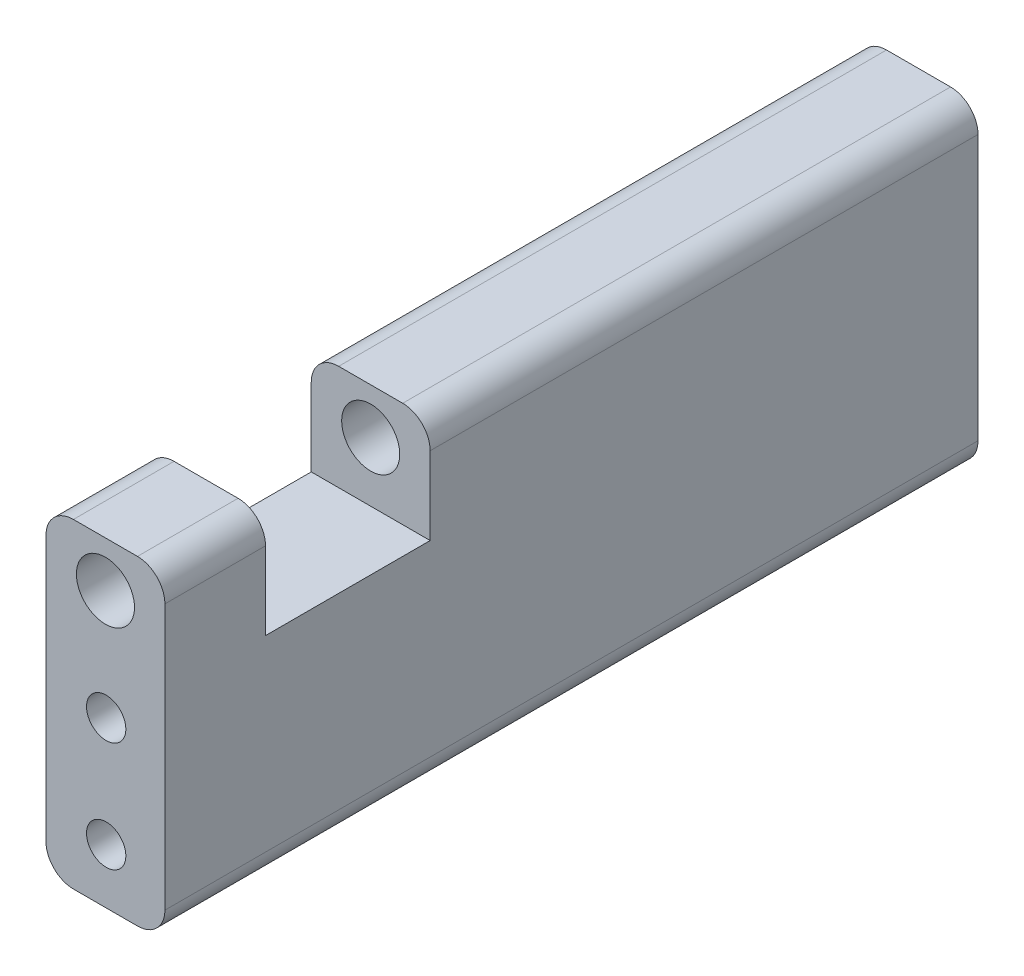
from build123d import *

# Parameters (mm, degrees)
SKETCH1_W                = 13
SKETCH1_H                = 35
SKETCH1_R                = 3.175
BOSS_EXTRUDE1_DEPTH      = 88.9
CUT_EXTRUDE1_DEPTH       = 9
M4_CLEARANCE_HOLE1_D     = 4.3
M4_CLEARANCE_HOLE1_DEPTH = 5
M4_CLEARANCE_HOLE1_TIP   = 1.291850331
M4_CLEARANCE_HOLE2_D     = 4.3
M4_CLEARANCE_HOLE2_DEPTH = 5
M4_CLEARANCE_HOLE2_TIP   = 1.291850331
FILLET1_R                = 3


with BuildPart() as part:
    # Sketch1 → Boss-Extrude1 (new body)
    with BuildSketch(Plane.XY):
        with Locations((6.5, 17.5)):
            Rectangle(SKETCH1_W, SKETCH1_H)
        with Locations((6.5, 30)):
            Circle(SKETCH1_R, mode=Mode.SUBTRACT)
    extrude(amount=BOSS_EXTRUDE1_DEPTH)

    # Sketch2 → Cut-Extrude1 (cut, symmetric)
    with BuildSketch(Plane.XY.offset(68.9)):
        Polygon((0, 30), (0, 35), (13, 35), (13, 30), (13, 23.5), (0, 23.5), align=None)
    extrude(amount=CUT_EXTRUDE1_DEPTH, both=True, mode=Mode.SUBTRACT)

    # M4 Clearance Hole1
    with Locations(Plane(origin=(0, 0, 0), x_dir=(-1, 0, 0), z_dir=(0, 0, -1))):
        with Locations((-6.579246302, 18), (-6.579246302, 6)):
            Hole(M4_CLEARANCE_HOLE1_D / 2, depth=M4_CLEARANCE_HOLE1_DEPTH)
            with Locations((0, 0, -(M4_CLEARANCE_HOLE1_DEPTH + M4_CLEARANCE_HOLE1_TIP / 2))):  # 118° drill point
                Cone(0, M4_CLEARANCE_HOLE1_D / 2, M4_CLEARANCE_HOLE1_TIP, mode=Mode.SUBTRACT)

    # M4 Clearance Hole2
    with Locations(Plane.XY.offset(88.9)):
        with Locations((6.579246302, 18), (6.579246302, 6)):
            Hole(M4_CLEARANCE_HOLE2_D / 2, depth=M4_CLEARANCE_HOLE2_DEPTH)
            with Locations((0, 0, -(M4_CLEARANCE_HOLE2_DEPTH + M4_CLEARANCE_HOLE2_TIP / 2))):  # 118° drill point
                Cone(0, M4_CLEARANCE_HOLE2_D / 2, M4_CLEARANCE_HOLE2_TIP, mode=Mode.SUBTRACT)

    # Fillet1
    fillet1_edges = [part.edges().sort_by_distance(p)[0] for p in [
        (0, 35, 29.95),
        (13, 35, 29.95),
        (0, 35, 83.4),
        (13, 35, 83.4),
        (13, 0, 44.45),
        (0, 0, 44.45),
    ]]
    fillet(fillet1_edges, radius=FILLET1_R)


solid = part.part
